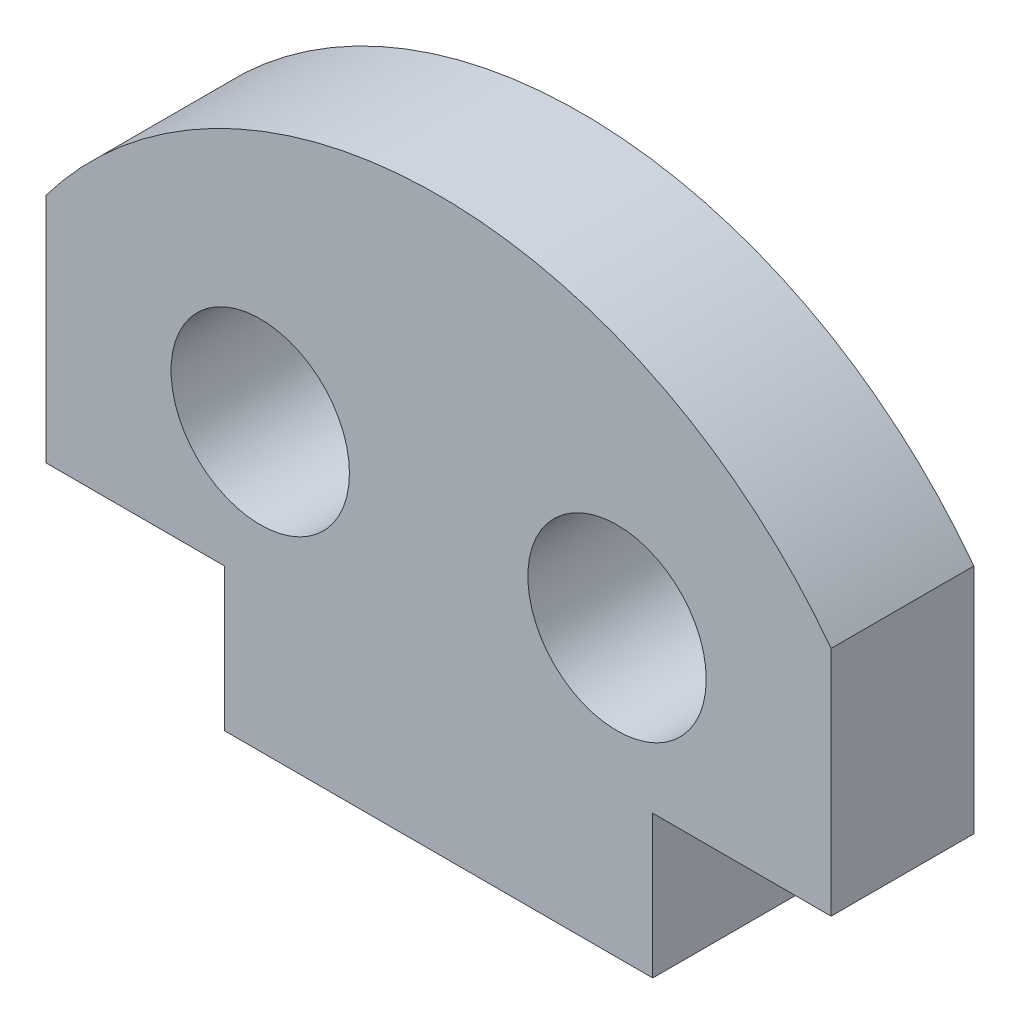
from build123d import *

# Parameters (mm, degrees)
MODEL_R             = 1.25
BOSS_EXTRUDE1_DEPTH = 2


with BuildPart() as part:
    # Model → Boss-Extrude1 (new body)
    with BuildSketch(Plane.XY):
        with BuildLine():
            Line((1953.676808721, 1458.884115951), (1951.176808721, 1458.884115951))
            Line((1951.176808721, 1458.884115951), (1951.176808721, 1462.134115951))
            ThreePointArc((1951.176808721, 1462.134115951), (1956.676808721, 1464.884115951), (1962.176808721, 1462.134115951))
            Line((1962.176808721, 1462.134115951), (1962.176808721, 1458.884115951))
            Line((1962.176808721, 1458.884115951), (1959.676808721, 1458.884115951))
            Line((1959.676808721, 1458.884115951), (1959.676808721, 1456.884115951))
            Line((1959.676808721, 1456.884115951), (1953.676808721, 1456.884115951))
            Line((1953.676808721, 1456.884115951), (1953.676808721, 1458.884115951))
        make_face()
        with Locations((1959.176808721, 1460.884115951)):
            Circle(MODEL_R, mode=Mode.SUBTRACT)
        with Locations((1954.176808721, 1460.884115951)):
            Circle(MODEL_R, mode=Mode.SUBTRACT)
    extrude(amount=BOSS_EXTRUDE1_DEPTH)


solid = part.part
